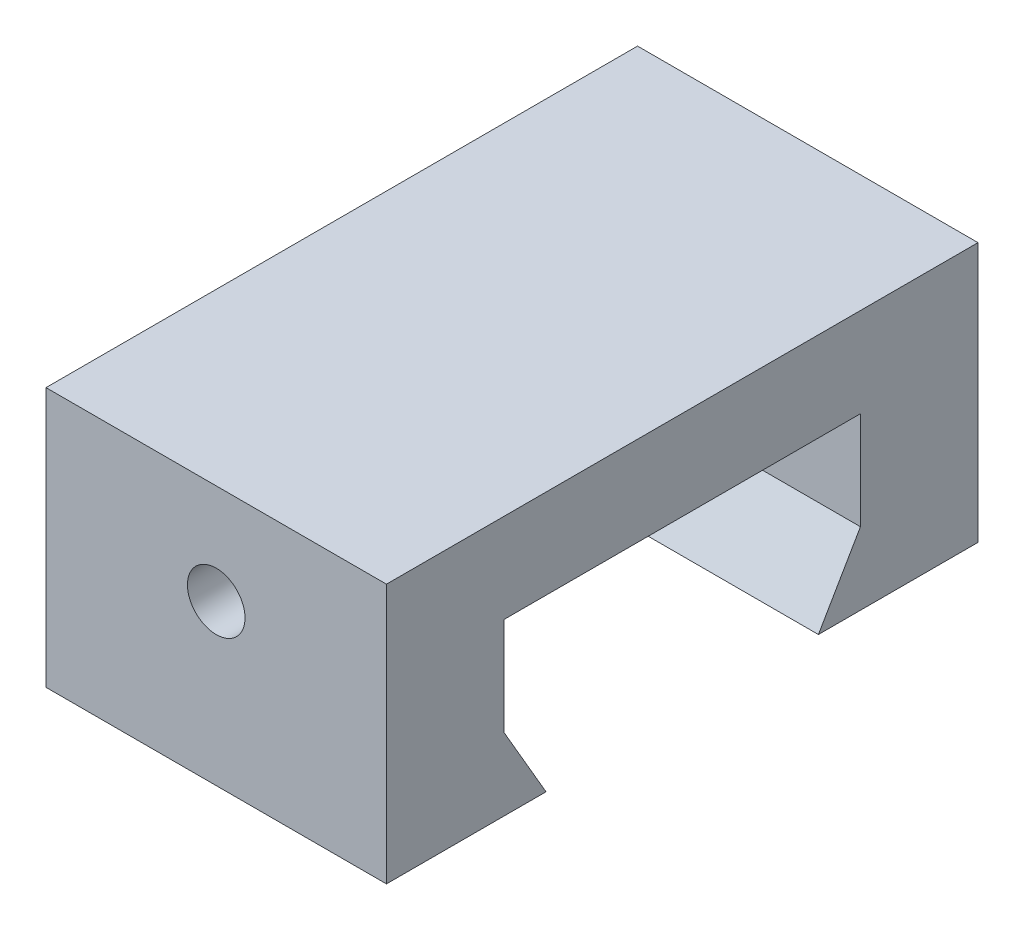
from build123d import *

# Parameters (mm, degrees)
BOSS_EXTRUDE1_DEPTH   = 8
F_6_32_TAPPED_HOLE1_D = 2.7051


with BuildPart() as part:
    # Sketch1 → Boss-Extrude1 (new, symmetric)
    with BuildSketch(Plane(origin=(0, 0, 0), x_dir=(0, 0, -1), z_dir=(1, 0, 0))):
        Polygon((-6.4, 0), (-8.375, 3.4), (-8.375, 8), (8.375, 8), (8.375, 3.4), (6.4, 0), (13.9, 0), (13.9, 12.2), (-13.9, 12.2), (-13.9, 0), align=None)
    extrude(amount=BOSS_EXTRUDE1_DEPTH, both=True)

    # 6-32 Tapped Hole1 (through all)
    with Locations(Plane.XY.offset(13.9)):
        with Locations((0, 7.5)):
            Hole(F_6_32_TAPPED_HOLE1_D / 2)


solid = part.part
